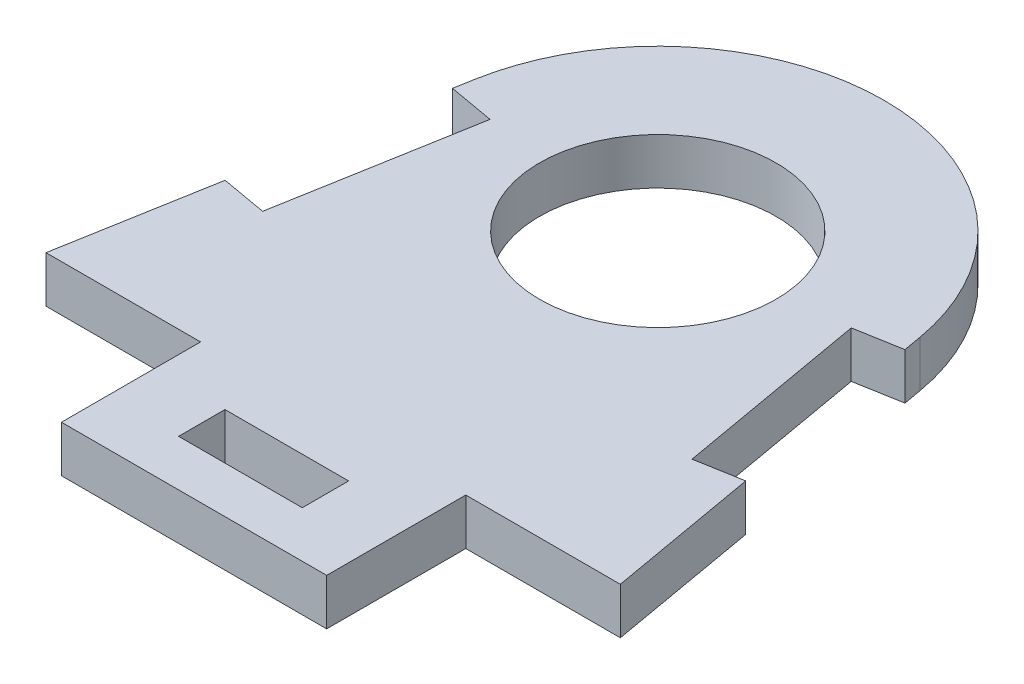
from build123d import *

# Parameters (mm, degrees)
SKETCH1_R           = 7.65
SKETCH1_W           = 8
SKETCH1_H           = 3
BOSS_EXTRUDE1_DEPTH = 1.5


with BuildPart() as part:
    # Sketch1 → Boss-Extrude1 (new, symmetric)
    with BuildSketch(Plane(origin=(0, 0, 0), x_dir=(1, 0, 0), z_dir=(0, 1, 0))):
        with BuildLine():
            Line((-16.842384682, 9.84807753), (-18.578866459, 0))
            Line((-18.578866459, 0), (-8.578866459, 0))
            Line((-8.578866459, 0), (-8.578866459, -9))
            Line((-8.578866459, -9), (8.578866459, -9))
            Line((8.578866459, -9), (8.578866459, 0))
            Line((8.578866459, 0), (18.578866459, 0))
            Line((18.578866459, 0), (16.842384682, 9.84807753))
            Line((16.842384682, 9.84807753), (13.887961423, 9.327132997))
            Line((13.887961423, 9.327132997), (11.682629567, 21.83419146))
            Line((11.682629567, 21.83419146), (14.637052826, 22.355135993))
            Line((14.637052826, 22.355135993), (14.427433582, 23.543945803))
            ThreePointArc((14.427433582, 23.543945803), (0, 35.65), (-14.427433582, 23.543945803))
            Line((-14.427433582, 23.543945803), (-14.637052826, 22.355135993))
            Line((-14.637052826, 22.355135993), (-11.682629567, 21.83419146))
            Line((-11.682629567, 21.83419146), (-13.887961423, 9.327132997))
            Line((-13.887961423, 9.327132997), (-16.842384682, 9.84807753))
        make_face()
        with Locations((0, 21)):
            Circle(SKETCH1_R, mode=Mode.SUBTRACT)
        with Locations((0, -4.5)):
            Rectangle(SKETCH1_W, SKETCH1_H, mode=Mode.SUBTRACT)
    extrude(amount=BOSS_EXTRUDE1_DEPTH, both=True)


solid = part.part
